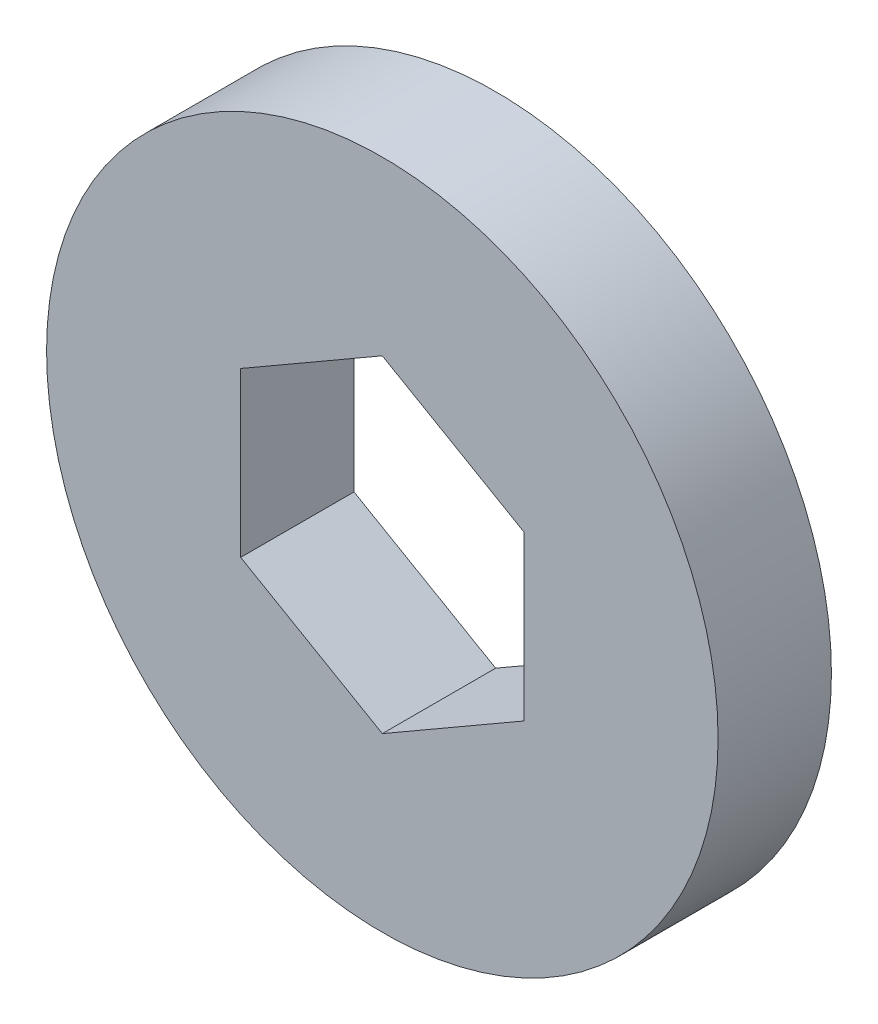
from build123d import *

# Parameters (mm, degrees)
SKETCH1_R           = 11.85
BOSS_EXTRUDE1_DEPTH = 4
CUT_EXTRUDE1_DEPTH  = 5


with BuildPart() as part:
    # Sketch1 → Boss-Extrude1 (new body)
    with BuildSketch(Plane.XY):
        Circle(SKETCH1_R)
    extrude(amount=BOSS_EXTRUDE1_DEPTH)

    # Sketch2 → Cut-Extrude1 (cut, through all)
    with BuildSketch(Plane(origin=(0, 0, 0), x_dir=(-1, 0, 0), z_dir=(0, 0, -1))):
        Polygon((0, 5.773502692), (-5, 2.886751346), (-5, -2.886751346), (0, -5.773502692), (5, -2.886751346), (5, 2.886751346), align=None)
    extrude(amount=-CUT_EXTRUDE1_DEPTH, mode=Mode.SUBTRACT)


solid = part.part
